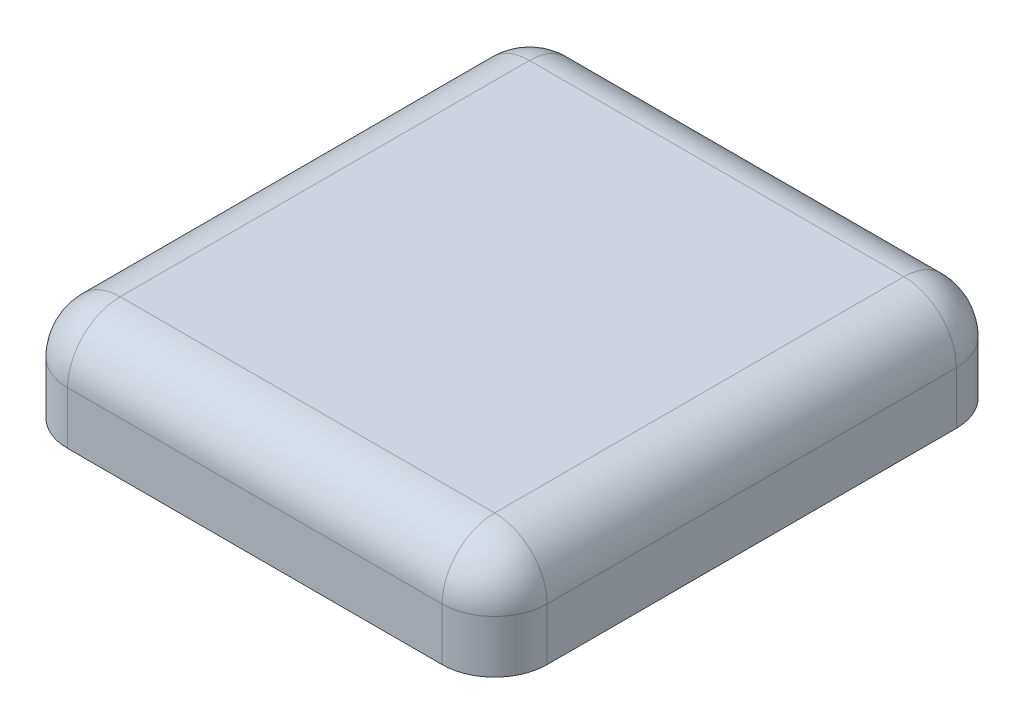
from build123d import *

# Parameters (mm, degrees)
SKETCH1_W                = 41
SKETCH1_H                = 45
BOSS_EXTRUDE1_DEPTH      = 2
SKETCH3_W                = 41
SKETCH3_H                = 2
BOSS_EXTRUDE2_DEPTH      = 10
SKETCH9_W                = 2
SKETCH9_H                = 48.933806043
BOSS_EXTRUDE6_DEPTH      = 10
SKETCH7_W                = 41
SKETCH7_H                = 1.933806043
BOSS_EXTRUDE7_DEPTH      = 8
BOSS_EXTRUDE7_DEPTH_BACK = 2
SKETCH10_W               = 2.62804999
SKETCH10_H               = 48.933806043
BOSS_EXTRUDE8_DEPTH      = 10
FILLET3_R                = 5
FILLET4_R                = 2


with BuildPart() as part:
    # Sketch1 → Boss-Extrude1 (new body)
    with BuildSketch(Plane(origin=(0, 0, 0), x_dir=(1, 0, 0), z_dir=(0, 1, 0))):
        with Locations((0.11627907, -1.098837209)):
            Rectangle(SKETCH1_W, SKETCH1_H)
    extrude(amount=BOSS_EXTRUDE1_DEPTH)

    # Sketch3 → Boss-Extrude2 (add)
    with BuildSketch(Plane(origin=(0, 2, 0), x_dir=(1, 0, 0), z_dir=(0, 1, 0))):
        with Locations((0.11627907, -24.598837209)):
            Rectangle(SKETCH3_W, SKETCH3_H)
    extrude(amount=-BOSS_EXTRUDE2_DEPTH)

    # Sketch9 → Boss-Extrude6 (add)
    with BuildSketch(Plane(origin=(0, 2, 0), x_dir=(1, 0, 0), z_dir=(0, 1, 0))):
        with Locations((-21.38372093, -1.131934188)):
            Rectangle(SKETCH9_W, SKETCH9_H)
    extrude(amount=-BOSS_EXTRUDE6_DEPTH)

    # Sketch7 → Boss-Extrude7 (add, two sides)
    with BuildSketch(Plane(origin=(0, 0, 0), x_dir=(-1, 0, 0), z_dir=(0, -1, 0))) as boss_extrude7_sk:
        with Locations((-0.11627907, 22.368065812)):
            Rectangle(SKETCH7_W, SKETCH7_H)
    extrude(amount=BOSS_EXTRUDE7_DEPTH)
    extrude(boss_extrude7_sk.sketch, amount=-BOSS_EXTRUDE7_DEPTH_BACK)

    # Sketch10 → Boss-Extrude8 (add)
    with BuildSketch(Plane(origin=(0, -8, 0), x_dir=(-1, 0, 0), z_dir=(0, -1, 0))):
        with Locations((-21.930304065, -1.131934188)):
            Rectangle(SKETCH10_W, SKETCH10_H)
    extrude(amount=-BOSS_EXTRUDE8_DEPTH)

    # Fillet3
    fillet3_edges = [part.edges().sort_by_distance(p)[0] for p in [
        (0.430304065, 2, 25.598837209),
        (-22.38372093, -3, 25.598837209),
        (-22.38372093, -3, -23.334968834),
        (0.430304065, 2, -23.334968834),
        (-22.38372093, 2, 1.131934188),
        (23.24432906, 2, 1.131934188),
        (23.24432906, -3, 25.598837209),
        (23.24432906, -3, -23.334968834),
    ]]
    fillet(fillet3_edges, radius=FILLET3_R)

    # Fillet4
    fillet4_edges = [part.edges().sort_by_distance(p)[0] for p in [
        (-20.38372093, -4, 23.598837209),
        (20.61627907, -4, 23.598837209),
        (-20.38372093, -4, -21.401162791),
        (20.61627907, -4, -21.401162791),
    ]]
    fillet(fillet4_edges, radius=FILLET4_R)


solid = part.part
